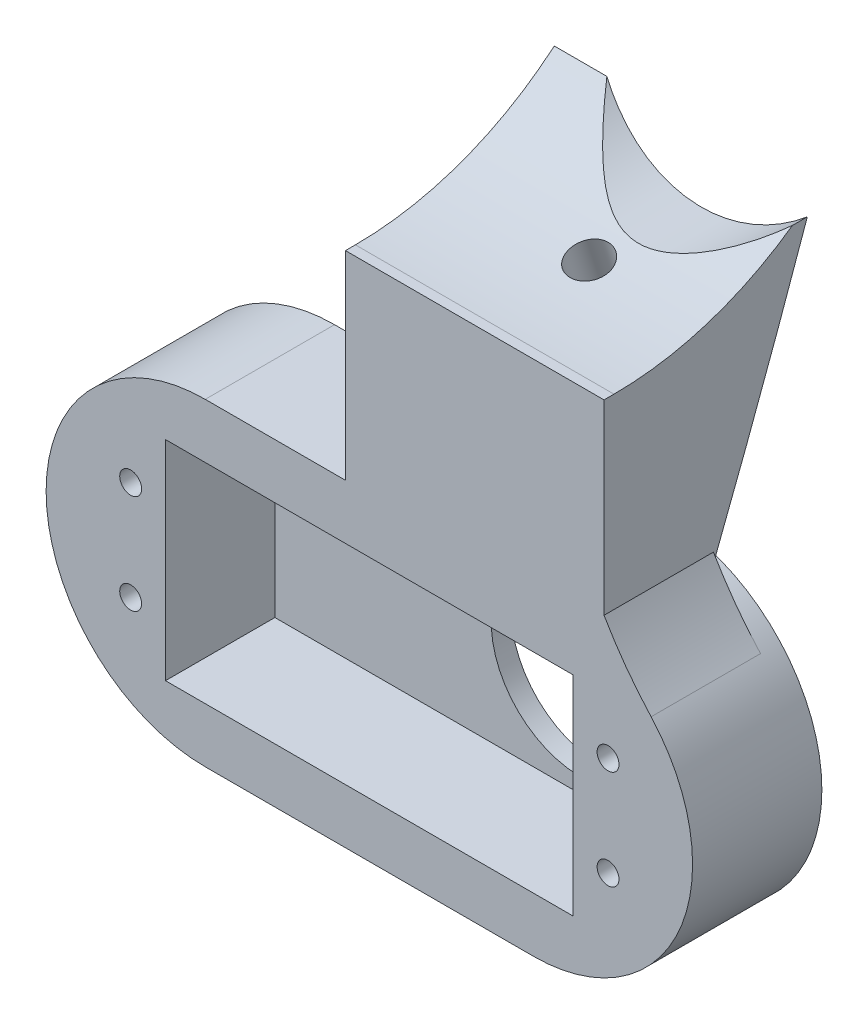
from build123d import *

# Parameters (mm, degrees)
SKETCH1_R               = 1.1
SKETCH1_W               = 41
SKETCH1_H               = 21
BOSS_EXTRUDE1_DEPTH     = 11
SKETCH2_R               = 9.000000034
BOSS_EXTRUDE2_DEPTH     = 2
BOSS_EXTRUDE3_DEPTH     = 10
BOSS_EXTRUDE4_DEPTH     = 26
SKETCH6_R               = 15.25
CUT_EXTRUDE1_DEPTH      = 11.0000001
SKETCH8_R               = 2
CUT_EXTRUDE3_DEPTH      = 33.905944515
CUT_EXTRUDE3_DEPTH_BACK = 30.994912665
SKETCH11_R              = 3.875
SKETCH11_R_2            = 2
CUT_EXTRUDE4_DEPTH      = 15.37
BOSS_EXTRUDE6_DEPTH     = 1


with BuildPart() as part:
    # Sketch1 → Boss-Extrude1 (new body)
    with BuildSketch(Plane.XY):
        with BuildLine():
            Line((4, -5.500000004), (37, -5.500000004))
            ThreePointArc((37, -5.500000004), (53.000000004, 10.5), (37, 26.500000004))
            Line((37, 26.500000004), (4, 26.500000004))
            ThreePointArc((4, 26.500000004), (-12.000000004, 10.5), (4, -5.500000004))
        make_face()
        with Locations((-3.5, 15.5)):
            Circle(SKETCH1_R, mode=Mode.SUBTRACT)
        with Locations((-3.5, 5.5)):
            Circle(SKETCH1_R, mode=Mode.SUBTRACT)
        with Locations((44.5, 5.5)):
            Circle(SKETCH1_R, mode=Mode.SUBTRACT)
        with Locations((44.5, 15.5)):
            Circle(SKETCH1_R, mode=Mode.SUBTRACT)
        with Locations((20.5, 10.5)):
            Rectangle(SKETCH1_W, SKETCH1_H, mode=Mode.SUBTRACT)
    extrude(amount=BOSS_EXTRUDE1_DEPTH)

    # Sketch2 → Boss-Extrude2 (add)
    with BuildSketch(Plane.XY):
        with BuildLine():
            Line((37, 26.500000004), (4, 26.500000004))
            ThreePointArc((4, 26.500000004), (-12.000000004, 10.5), (4, -5.500000004))
            Line((4, -5.500000004), (37, -5.500000004))
            ThreePointArc((37, -5.500000004), (53.000000004, 10.5), (37, 26.500000004))
        make_face()
        with Locations((30.749999966, 10.5)):
            Circle(SKETCH2_R, mode=Mode.SUBTRACT)
    extrude(amount=-BOSS_EXTRUDE2_DEPTH)

    # Sketch3 → Boss-Extrude3 (add)
    with BuildSketch(Plane.XY):
        with BuildLine():
            Line((37, 26.500000004), (18.095900106, 26.500000004))
            Line((18.095900106, 26.500000004), (18.095900106, 46.500000004))
            Line((18.095900106, 46.500000004), (44.095900176, 46.500000004))
            Line((44.095900176, 46.500000004), (44.095900176, 27.744899316))
            ThreePointArc((44.095900176, 27.744899316), (46.289330037, 24.381962762), (48.82982939, 21.272888969))
            ThreePointArc((48.82982939, 21.272888969), (43.466597892, 25.134996134), (37, 26.500000004))
        make_face()
    extrude(amount=BOSS_EXTRUDE3_DEPTH)

    # Sketch5 → Boss-Extrude4 (add)
    with BuildSketch(Plane(origin=(44.095900176, 0, 0), x_dir=(0, 0, -1), z_dir=(1, 0, 0))):
        with BuildLine():
            Line((0, 26.737992109), (-10, 46.500000004))
            ThreePointArc((-10, 46.500000004), (0.647802696, 48.386011996), (10, 53.814561439))
            add(Edge.make_bspline(
                [(0, 26.737992109), (5.263715072, 40.18126942), (10, 53.814561439)],
                knots=[0, 0, 0, 1, 1, 1], degree=2))
        make_face()
    extrude(amount=-BOSS_EXTRUDE4_DEPTH)

    # Sketch6 → Cut-Extrude1 (cut, through all)
    with BuildSketch(Plane.XY):
        with Locations((34.595900106, 64.15000003)):
            Circle(SKETCH6_R)
    extrude(amount=-CUT_EXTRUDE1_DEPTH, mode=Mode.SUBTRACT)

    # Sketch8 → Cut-Extrude3 (cut, two sides)
    with BuildSketch(Plane(origin=(0, 23.381689927, 7.597171588), x_dir=(-1, 0, 0), z_dir=(0, -0.951056516, -0.309016994))) as cut_extrude3_sk:
        with Locations((-32.562075151, 13.880413242)):
            Circle(SKETCH8_R)
    extrude(amount=CUT_EXTRUDE3_DEPTH, mode=Mode.SUBTRACT)
    extrude(cut_extrude3_sk.sketch, amount=-CUT_EXTRUDE3_DEPTH_BACK, mode=Mode.SUBTRACT)

    # Sketch11 → Cut-Extrude4 (cut)
    with BuildSketch(Plane(origin=(0, 33.367783426, 10.841850055), x_dir=(-1, 0, 0), z_dir=(0, -0.951056516, -0.309016994))):
        with Locations((-32.562075151, 13.880413242)):
            Circle(SKETCH11_R)
        with Locations((-32.562075151, 13.880413242)):
            Circle(SKETCH11_R_2, mode=Mode.SUBTRACT)
    extrude(amount=CUT_EXTRUDE4_DEPTH, mode=Mode.SUBTRACT)

    # Sketch12 → Boss-Extrude6 (add)
    with BuildSketch(Plane.XY.offset(10)):
        with BuildLine():
            Line((44.095900176, 27.744899316), (44.095900176, 46.500000004))
            Line((44.095900176, 46.500000004), (18.095900106, 46.500000004))
            Line((18.095900106, 46.500000004), (18.095900106, 26.500000004))
            Line((18.095900106, 26.500000004), (37, 26.500000004))
            ThreePointArc((37, 26.500000004), (43.466597892, 25.134996134), (48.82982939, 21.272888969))
            ThreePointArc((48.82982939, 21.272888969), (46.289330037, 24.381962762), (44.095900176, 27.744899316))
        make_face()
    extrude(amount=BOSS_EXTRUDE6_DEPTH)


solid = part.part
